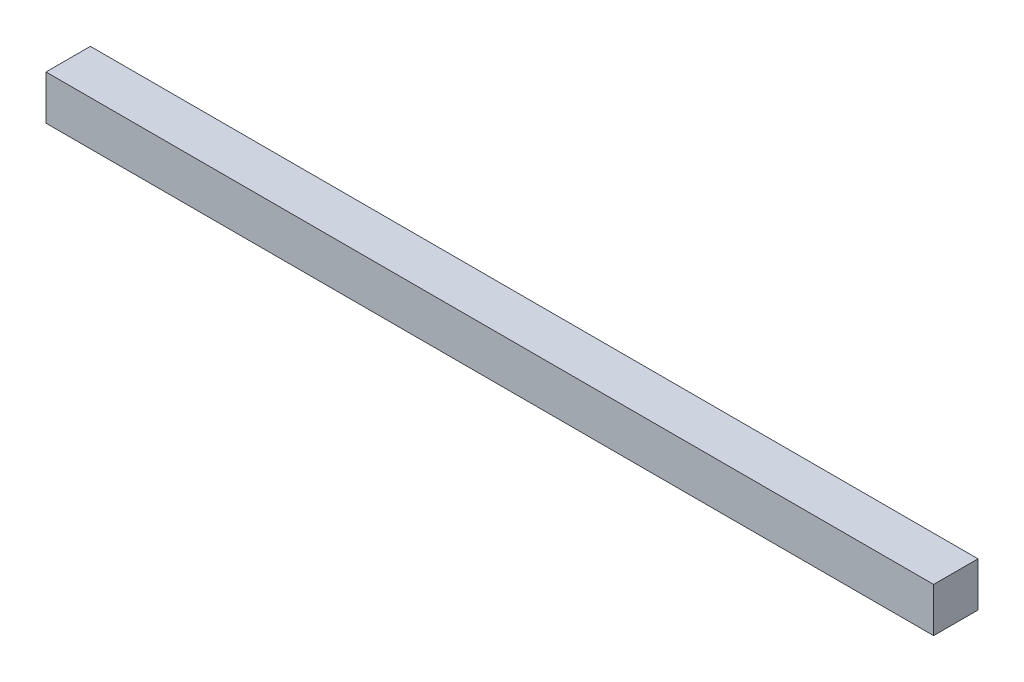
from build123d import *

# Parameters (mm, degrees)
SKETCH1_W           = 200
SKETCH1_H           = 10
BOSS_EXTRUDE1_DEPTH = 10


with BuildPart() as part:
    # Sketch1 → Boss-Extrude1 (new body)
    with BuildSketch(Plane.XY):
        with Locations((100, 5)):
            Rectangle(SKETCH1_W, SKETCH1_H)
    extrude(amount=BOSS_EXTRUDE1_DEPTH)


solid = part.part
